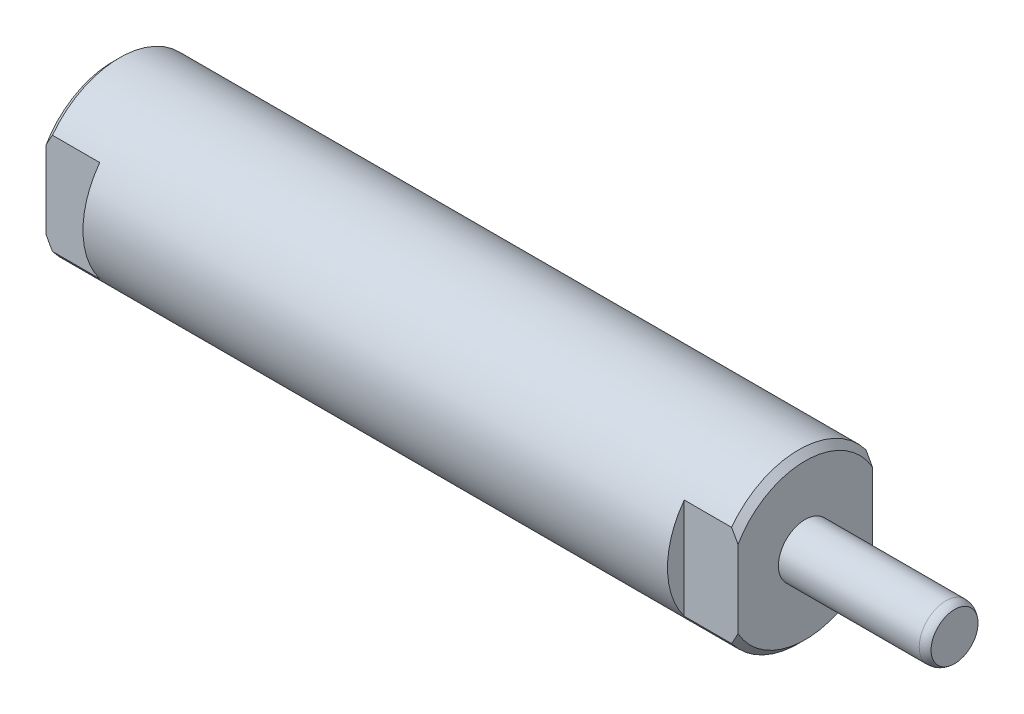
from build123d import *

# Parameters (mm, degrees)
CHAMFER1_SIZE           = 0.762
SKETCH5_W               = 6.35
SKETCH5_H               = 1.981
CUT_EXTRUDE1_DEPTH      = 10.9185
CUT_EXTRUDE1_DEPTH_BACK = 10.9185
SKETCH6_W               = 6.35
SKETCH6_H               = 1.981
CUT_EXTRUDE2_DEPTH      = 10.9185
CUT_EXTRUDE2_DEPTH_BACK = 10.9185


with BuildPart() as part:
    # Sketch1 → Revolve1 (revolve)
    with BuildSketch(Plane(origin=(0, 0, 0), x_dir=(-1, 0, 0), z_dir=(0, 0, -1)), mode=Mode.PRIVATE) as revolve1_sk:
        with BuildLine():
            Line((-99.4156, 2.774222533), (-99.4156, 0))
            Line((-99.4156, 0), (0, 0))
            Line((0, 0), (0, 9.9185))
            Line((0, 9.9185), (-81.7626, 9.9185))
            Line((-81.7626, 9.9185), (-81.7626, 3.1623))
            Line((-81.7626, 3.1623), (-98.3996, 3.1623))
            ThreePointArc((-98.3996, 3.1623), (-98.943396865, 3.061978675), (-99.4156, 2.774222533))
        make_face()
    revolve(revolve1_sk.sketch.rotate(Axis((99.4156, 0, 0), (-1, 0, 0)), 270), axis=Axis((99.4156, 0, 0), (-1, 0, 0)))  # turned: the seam where the file's is

    # Sketch2 → Cut-Revolve1 (revolve, cut)
    with BuildSketch(Plane(origin=(0, 0, 0), x_dir=(-1, 0, 0), z_dir=(0, 0, -1)), mode=Mode.PRIVATE) as cut_revolve1_sk:
        Polygon((0, 0), (0, 4.953), (-0.127, 4.953), (-0.6604, 4.4196), (-10.5664, 4.4196), (-10.5664, 0), align=None)
    revolve(cut_revolve1_sk.sketch.rotate(Axis((0, 0, 0), (1, 0, 0)), 90), axis=Axis((0, 0, 0), (1, 0, 0)), mode=Mode.SUBTRACT)  # turned: the seam where the file's is

    # Chamfer1
    chamfer1_edges = [part.edges().sort_by_distance(p)[0] for p in [
        (81.7626, 0, -9.9185),
        (0, 0, -9.9185),
    ]]
    chamfer(chamfer1_edges, length=CHAMFER1_SIZE)

    # Sketch5 → Cut-Extrude1 (cut, two sides)
    with BuildSketch(Plane(origin=(0, 0, 0), x_dir=(1, 0, 0), z_dir=(0, 1, 0))) as cut_extrude1_sk:
        with Locations((3.175, 8.928)):
            Rectangle(SKETCH5_W, SKETCH5_H)
        with Locations((3.175, -8.928)):
            Rectangle(SKETCH5_W, SKETCH5_H)
    extrude(amount=CUT_EXTRUDE1_DEPTH, mode=Mode.SUBTRACT)
    extrude(cut_extrude1_sk.sketch, amount=-CUT_EXTRUDE1_DEPTH_BACK, mode=Mode.SUBTRACT)

    # Sketch6 → Cut-Extrude2 (cut, two sides)
    with BuildSketch(Plane(origin=(0, 0, 0), x_dir=(1, 0, 0), z_dir=(0, 1, 0))) as cut_extrude2_sk:
        with Locations((78.5876, 8.928)):
            Rectangle(SKETCH6_W, SKETCH6_H)
        with Locations((78.5876, -8.928)):
            Rectangle(SKETCH6_W, SKETCH6_H)
    extrude(amount=CUT_EXTRUDE2_DEPTH, mode=Mode.SUBTRACT)
    extrude(cut_extrude2_sk.sketch, amount=-CUT_EXTRUDE2_DEPTH_BACK, mode=Mode.SUBTRACT)


solid = part.part
